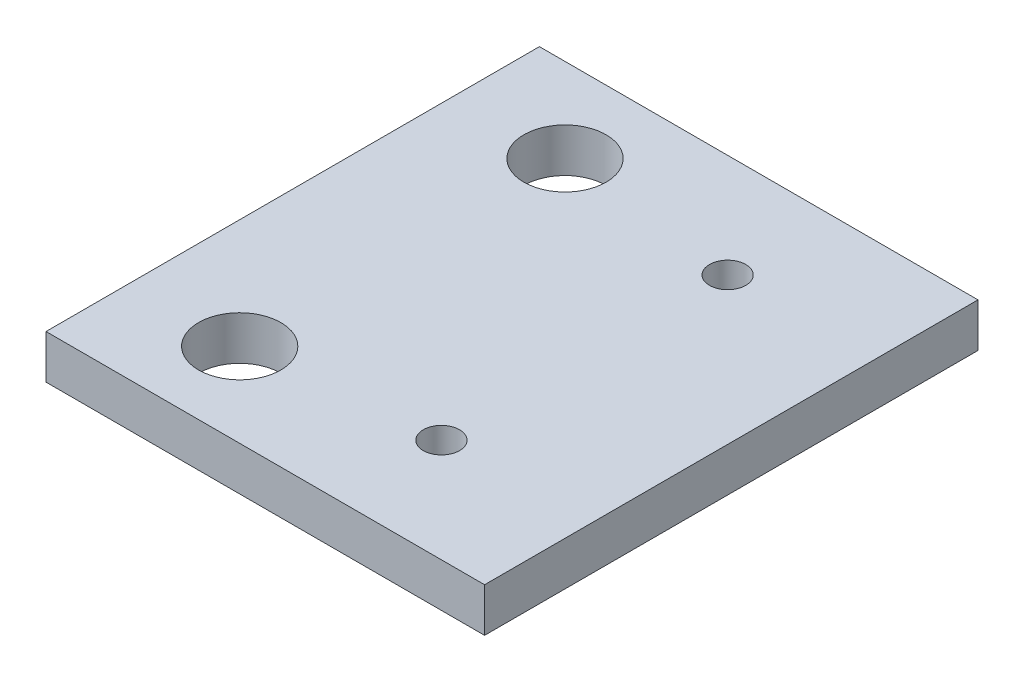
from build123d import *

# Parameters (mm, degrees)
SKETCH1_W           = 50.8
SKETCH1_H           = 57.15
BOSS_EXTRUDE1_DEPTH = 5.08
SKETCH2_R           = 4.7625
CUT_EXTRUDE1_DEPTH  = 5.08
SKETCH3_R           = 2.1
CUT_EXTRUDE3_DEPTH  = 6.08


with BuildPart() as part:
    # Sketch1 → Boss-Extrude1 (new body)
    with BuildSketch(Plane(origin=(0, 0, 0), x_dir=(1, 0, 0), z_dir=(0, 1, 0))):
        Rectangle(SKETCH1_W, SKETCH1_H)
    extrude(amount=BOSS_EXTRUDE1_DEPTH)

    # Sketch2 → Cut-Extrude1 (cut)
    with BuildSketch(Plane(origin=(0, 5.08, 0), x_dir=(1, 0, 0), z_dir=(0, 1, 0))):
        with Locations((-12.7, 18.837656)):
            Circle(SKETCH2_R)
        with Locations((-12.7, -18.837656)):
            Circle(SKETCH2_R)
    extrude(amount=-CUT_EXTRUDE1_DEPTH, mode=Mode.SUBTRACT)

    # Sketch3 → Cut-Extrude3 (cut, through all)
    with BuildSketch(Plane.XZ):
        with Locations((8.4, -16.575)):
            Circle(SKETCH3_R)
        with Locations((8.4, 16.575)):
            Circle(SKETCH3_R)
    extrude(amount=-CUT_EXTRUDE3_DEPTH, mode=Mode.SUBTRACT)


solid = part.part
